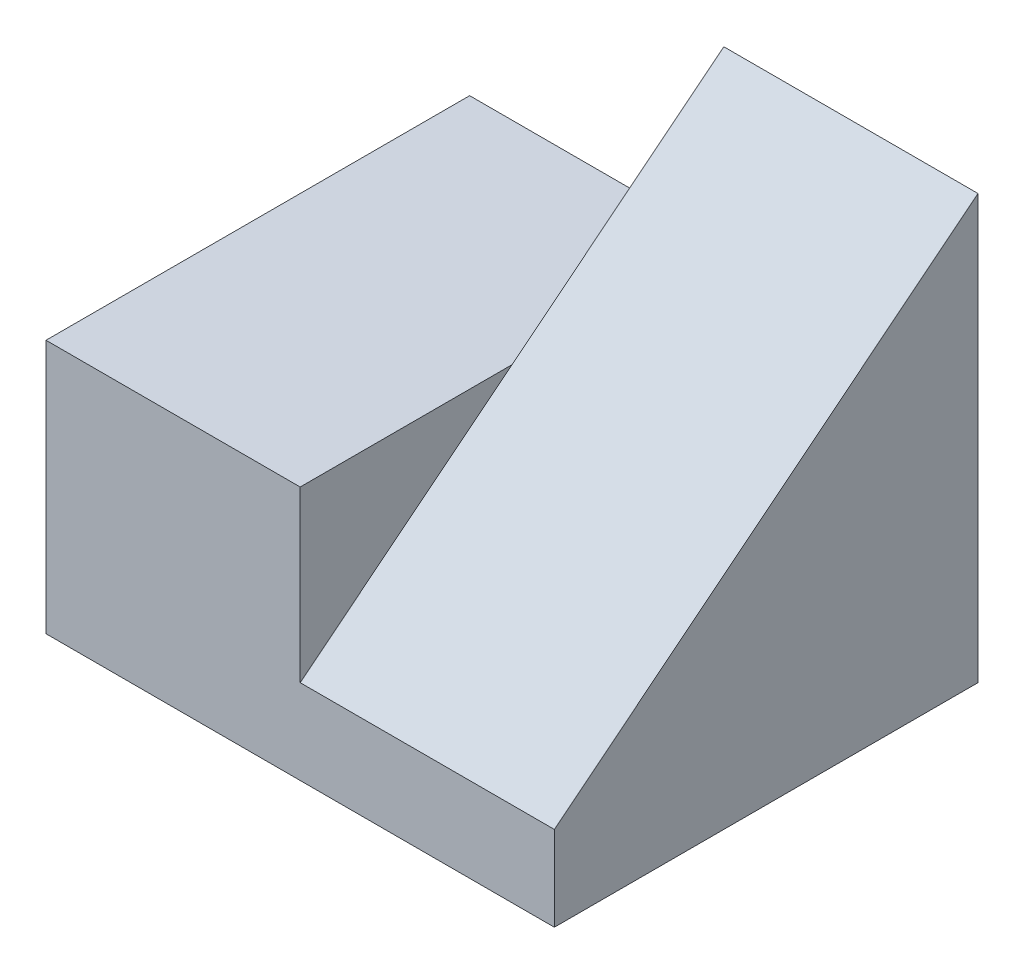
from build123d import *

# Parameters (mm, degrees)
BOSS_EXTRUDE1_DEPTH = 25
BOSS_EXTRUDE2_DEPTH = 15


with BuildPart() as part:
    # Sketch1 → Boss-Extrude1 (new body)
    with BuildSketch(Plane.XY):
        Polygon((0, 0), (0, 15), (15, 15), (15, 5), (30, 5), (30, 0), align=None)
    extrude(amount=BOSS_EXTRUDE1_DEPTH)

    # Sketch2 → Boss-Extrude2 (add)
    with BuildSketch(Plane(origin=(15, 0, 0), x_dir=(0, 0, -1), z_dir=(1, 0, 0))):
        Polygon((-25, 5), (0, 25), (0, 5), align=None)
    extrude(amount=BOSS_EXTRUDE2_DEPTH)


solid = part.part
